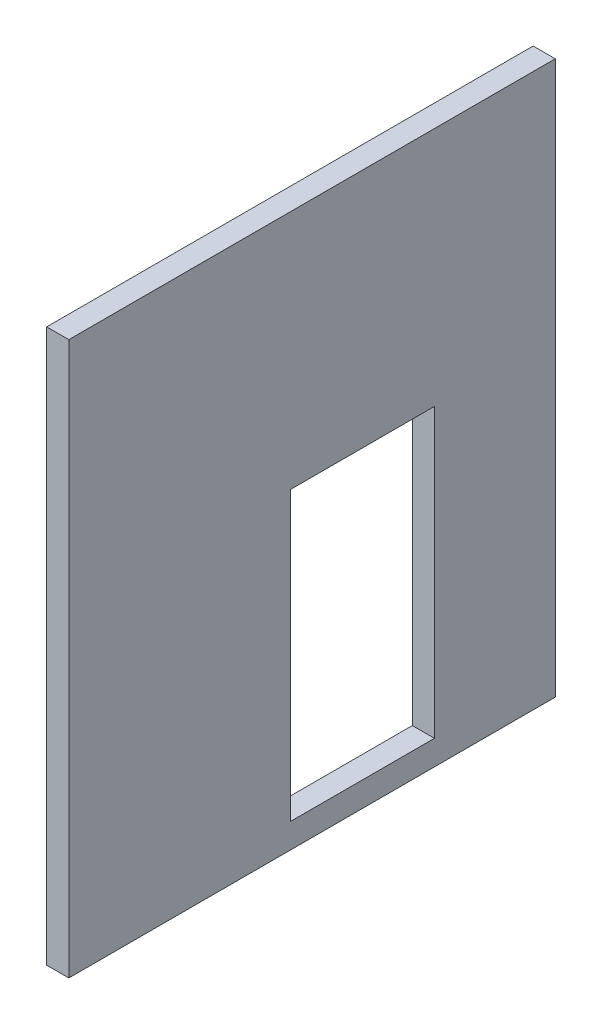
from build123d import *

# Parameters (mm, degrees)
ESQUISSE1_W             = 440
ESQUISSE1_H             = 500
BOSS_EXTRU_1_DEPTH      = 20
ESQUISSE3_W             = 130
ESQUISSE3_H             = 260
ENL_V_MAT_EXTRU_1_DEPTH = 20


with BuildPart() as part:
    # Esquisse1 → Boss.-Extru.1 (new body)
    with BuildSketch(Plane(origin=(0, 0, 0), x_dir=(0, 0, -1), z_dir=(1, 0, 0))):
        Rectangle(ESQUISSE1_W, ESQUISSE1_H)
    extrude(amount=BOSS_EXTRU_1_DEPTH)

    # Esquisse3 → Enlèv. mat.-Extru.1 (cut)
    with BuildSketch(Plane(origin=(20, 0, 0), x_dir=(0, 0, -1), z_dir=(1, 0, 0))):
        with Locations((45.664259244, -97.618983289)):
            Rectangle(ESQUISSE3_W, ESQUISSE3_H)
    extrude(amount=-ENL_V_MAT_EXTRU_1_DEPTH, mode=Mode.SUBTRACT)


solid = part.part
